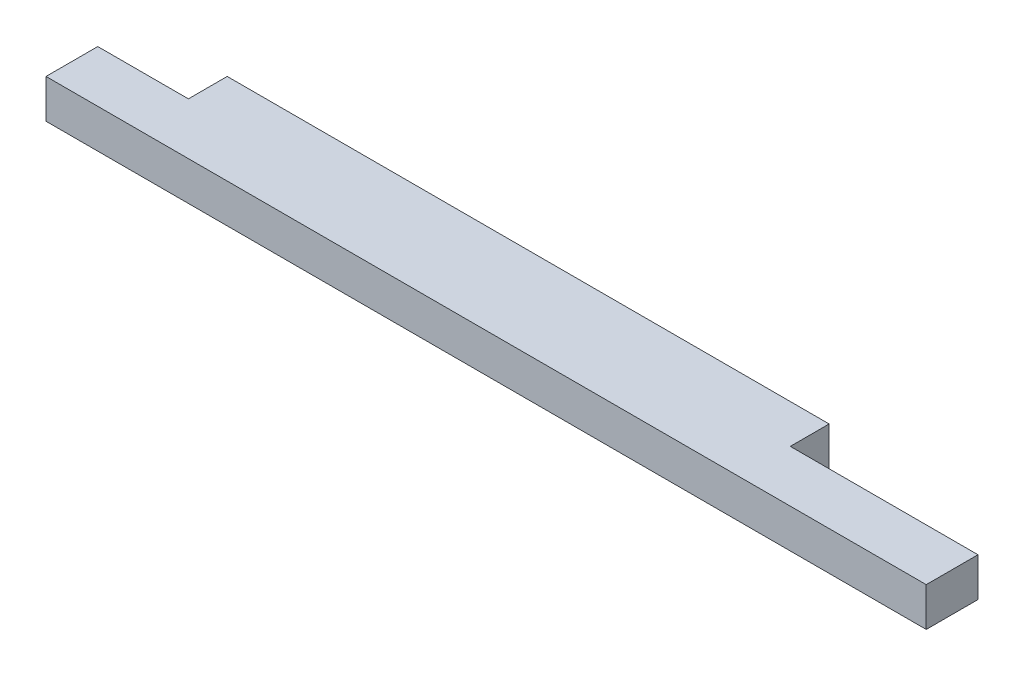
from build123d import *

# Parameters (mm, degrees)
SKETCH1_W           = 863.6
SKETCH1_H           = 88.9
BOSS_EXTRUDE1_DEPTH = 38.1
SKETCH3_W           = 184.15
SKETCH3_H           = 38.1
CUT_EXTRUDE1_DEPTH  = 39.1
SKETCH4_W           = 88.9
SKETCH4_H           = 38.1
CUT_EXTRUDE2_DEPTH  = 39.1


with BuildPart() as part:
    # Sketch1 → Boss-Extrude1 (new body)
    with BuildSketch(Plane(origin=(0, 0, 0), x_dir=(1, 0, 0), z_dir=(0, 1, 0))):
        with Locations((431.8, 44.45)):
            Rectangle(SKETCH1_W, SKETCH1_H)
    extrude(amount=BOSS_EXTRUDE1_DEPTH)

    # Sketch3 → Cut-Extrude1 (cut, through all)
    with BuildSketch(Plane(origin=(0, 38.1, 0), x_dir=(1, 0, 0), z_dir=(0, 1, 0))):
        with Locations((771.525, 69.85)):
            Rectangle(SKETCH3_W, SKETCH3_H)
    extrude(amount=-CUT_EXTRUDE1_DEPTH, mode=Mode.SUBTRACT)

    # Sketch4 → Cut-Extrude2 (cut, through all)
    with BuildSketch(Plane(origin=(0, 38.1, 0), x_dir=(1, 0, 0), z_dir=(0, 1, 0))):
        with Locations((44.45, 69.85)):
            Rectangle(SKETCH4_W, SKETCH4_H)
    extrude(amount=-CUT_EXTRUDE2_DEPTH, mode=Mode.SUBTRACT)


solid = part.part
